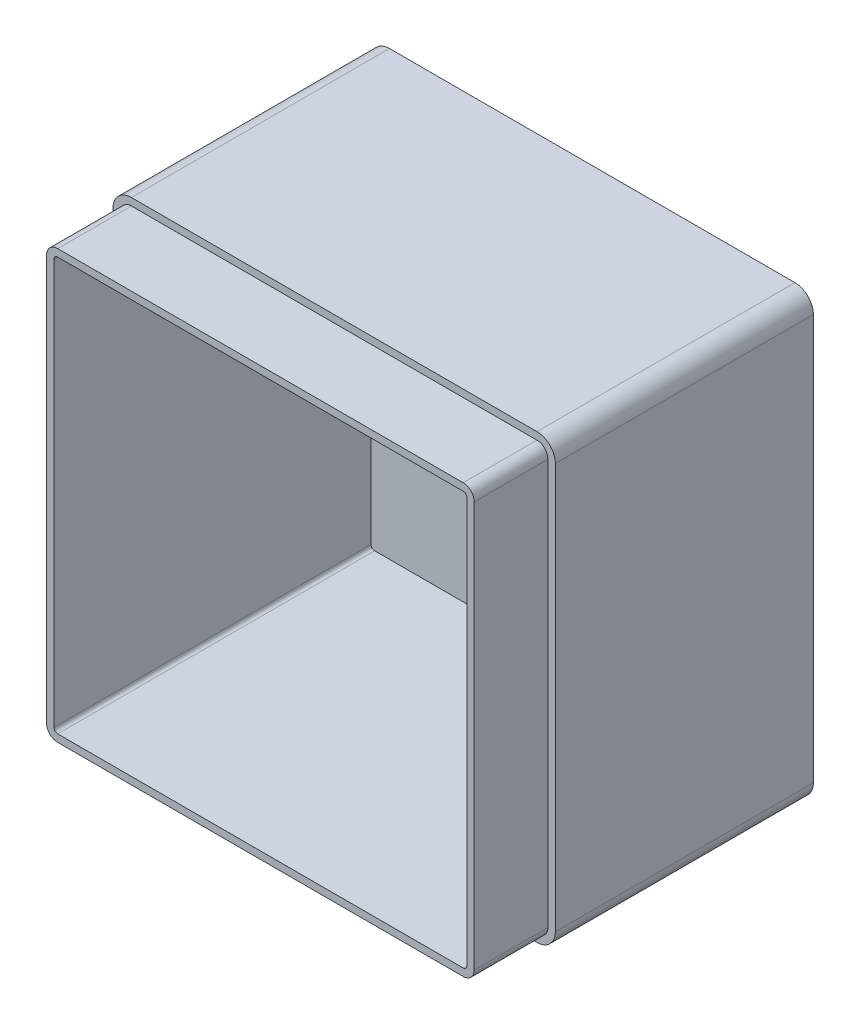
from build123d import *

# Parameters (mm, degrees)
SKETCH1_W           = 120
SKETCH1_H           = 120
BOSS_EXTRUDE1_DEPTH = 90
FILLET1_R           = 5
SHELL1_T            = -4
CUT_EXTRUDE1_DEPTH  = 20


with BuildPart() as part:
    # Sketch1 → Boss-Extrude1 (new body)
    with BuildSketch(Plane.XY):
        with Locations((60, -60)):
            Rectangle(SKETCH1_W, SKETCH1_H)
    extrude(amount=BOSS_EXTRUDE1_DEPTH)

    # Fillet1
    fillet1_edges = [part.edges().sort_by_distance(p)[0] for p in [
        (0, 0, 45),
        (120, 0, 45),
        (120, -120, 45),
        (0, -120, 45),
    ]]
    fillet(fillet1_edges, radius=FILLET1_R)

    # Shell1
    shell1_openings = [part.faces().sort_by_distance(p)[0] for p in [
        (60, -60, 90),
    ]]
    offset(amount=SHELL1_T, openings=shell1_openings, kind=Kind.INTERSECTION)

    # Sketch3 → Cut-Extrude1 (cut)
    with BuildSketch(Plane.XY.offset(90)):
        with BuildLine():
            Line((0, -5), (0, -115))
            ThreePointArc((0, -115), (1.464466094, -118.535533906), (5, -120))
            Line((5, -120), (115, -120))
            ThreePointArc((115, -120), (118.535533906, -118.535533906), (120, -115))
            Line((120, -115), (120, -5))
            ThreePointArc((120, -5), (118.535533906, -1.464466094), (115, 0))
            Line((115, 0), (5, 0))
            ThreePointArc((5, 0), (1.464466094, -1.464466094), (0, -5))
        make_face()
        with BuildLine():
            Line((2, -5), (2, -115))
            ThreePointArc((2, -115), (2.878679656, -117.121320344), (5, -118))
            Line((5, -118), (115, -118))
            ThreePointArc((115, -118), (117.121320344, -117.121320344), (118, -115))
            Line((118, -115), (118, -5))
            ThreePointArc((118, -5), (117.121320344, -2.878679656), (115, -2))
            Line((115, -2), (5, -2))
            ThreePointArc((5, -2), (2.878679656, -2.878679656), (2, -5))
        make_face(mode=Mode.SUBTRACT)
    extrude(amount=-CUT_EXTRUDE1_DEPTH, mode=Mode.SUBTRACT)


solid = part.part
